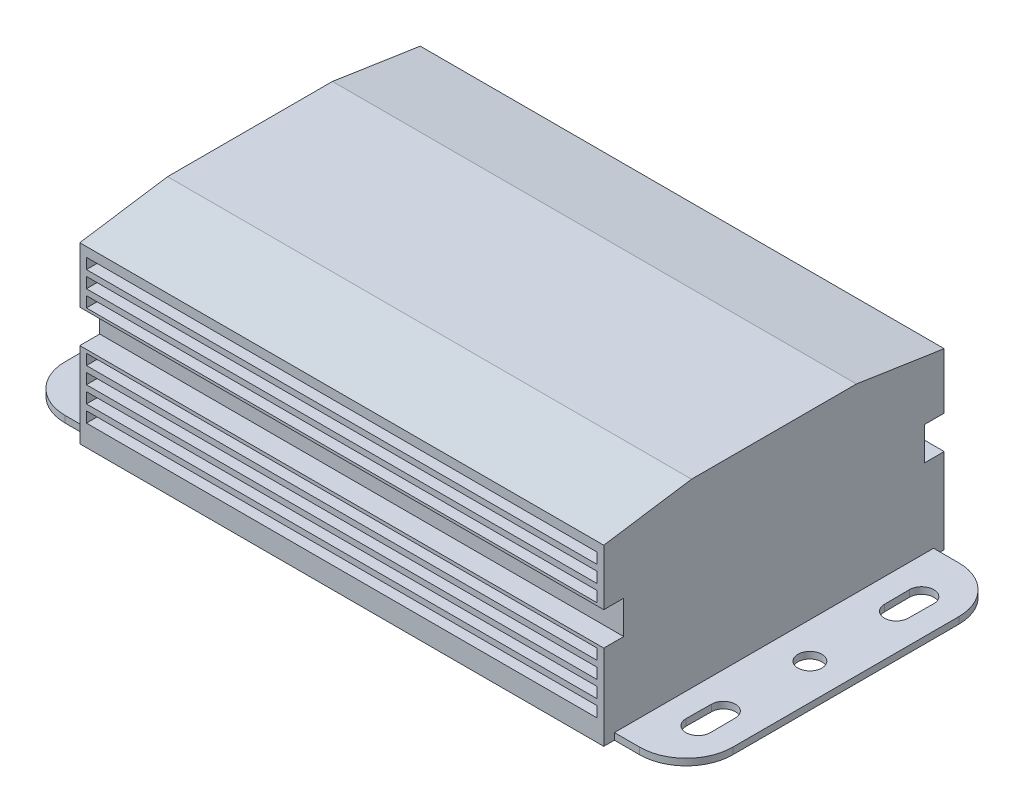
from build123d import *

# Parameters (mm, degrees)
SKETCH1_R               = 2.286
BOSS_EXTRUDE1_DEPTH     = 35.814
SKETCH3_W               = 13.716
SKETCH3_H               = 60.96
CUT_EXTRUDE2_DEPTH      = 34.544
SKETCH4_W               = 3.81
SKETCH4_H               = 6.35
CUT_EXTRUDE3_DEPTH      = 114.792
SKETCH5_W               = 97.536
SKETCH5_H               = 2.032
CUT_EXTRUDE6_DEPTH      = 3.048
LPATTERN1_COUNT         = 9
LPATTERN1_PITCH         = 3.175
MIRROR1_COPY_1_SKETCH_W = 97.536
MIRROR1_COPY_1_SKETCH_H = 2.032
MIRROR1_COPY_1_DEPTH    = 3.048
MIRROR1_COPY_2_SKETCH_W = 97.536
MIRROR1_COPY_2_SKETCH_H = 2.032
MIRROR1_COPY_2_DEPTH    = 3.048
MIRROR1_COPY_3_SKETCH_W = 97.536
MIRROR1_COPY_3_SKETCH_H = 2.032
MIRROR1_COPY_3_DEPTH    = 3.048
MIRROR1_COPY_4_SKETCH_W = 97.536
MIRROR1_COPY_4_SKETCH_H = 2.032
MIRROR1_COPY_4_DEPTH    = 3.048
MIRROR1_COPY_5_SKETCH_W = 97.536
MIRROR1_COPY_5_SKETCH_H = 2.032
MIRROR1_COPY_5_DEPTH    = 3.048
MIRROR1_COPY_6_SKETCH_W = 97.536
MIRROR1_COPY_6_SKETCH_H = 2.032
MIRROR1_COPY_6_DEPTH    = 3.048


with BuildPart() as part:
    # Sketch1 → Boss-Extrude1 (new body)
    with BuildSketch(Plane(origin=(0, 0, 0), x_dir=(1, 0, 0), z_dir=(0, 1, 0))):
        with BuildLine():
            Line((0, 11.938), (0, 55.118))
            ThreePointArc((0, 55.118), (-2.603820715, 61.404179285), (-8.89, 64.008))
            Line((-8.89, 64.008), (-13.716, 64.008))
            Line((-13.716, 64.008), (-13.716, 66.04))
            Line((-13.716, 66.04), (-113.792, 66.04))
            Line((-113.792, 66.04), (-113.792, 64.008))
            Line((-113.792, 64.008), (-118.618, 64.008))
            ThreePointArc((-118.618, 64.008), (-124.904179285, 61.404179285), (-127.508, 55.118))
            Line((-127.508, 55.118), (-127.508, 11.938))
            ThreePointArc((-127.508, 11.938), (-124.904179285, 5.651820715), (-118.618, 3.048))
            Line((-118.618, 3.048), (-113.792, 3.048))
            Line((-113.792, 3.048), (-113.792, 1.016))
            Line((-113.792, 1.016), (-13.716, 1.016))
            Line((-13.716, 1.016), (-13.716, 3.048))
            Line((-13.716, 3.048), (-8.89, 3.048))
            ThreePointArc((-8.89, 3.048), (-2.603820715, 5.651820715), (0, 11.938))
        make_face()
        with Locations((-120.65, 33.528)):
            Circle(SKETCH1_R, mode=Mode.SUBTRACT)
        with Locations((-6.858, 33.528)):
            Circle(SKETCH1_R, mode=Mode.SUBTRACT)
        with BuildLine():
            Line((-118.367709413, 17.018), (-118.325280939, 12.192))
            ThreePointArc((-118.325280939, 12.192), (-120.65, 9.867280939), (-122.974719061, 12.192))
            Line((-122.974719061, 12.192), (-122.932290587, 17.018))
            ThreePointArc((-122.932290587, 17.018), (-120.65, 19.300290587), (-118.367709413, 17.018))
        make_face(mode=Mode.SUBTRACT)
        with BuildLine():
            Line((-122.974719061, 54.864), (-122.932290587, 50.038))
            ThreePointArc((-122.932290587, 50.038), (-120.65, 47.755709413), (-118.367709413, 50.038))
            Line((-118.367709413, 50.038), (-118.325280939, 54.864))
            ThreePointArc((-118.325280939, 54.864), (-120.65, 57.188719061), (-122.974719061, 54.864))
        make_face(mode=Mode.SUBTRACT)
        with BuildLine():
            Line((-9.140290587, 50.038), (-9.182719061, 54.864))
            ThreePointArc((-9.182719061, 54.864), (-6.858, 57.188719061), (-4.533280939, 54.864))
            Line((-4.533280939, 54.864), (-4.575709413, 50.038))
            ThreePointArc((-4.575709413, 50.038), (-6.858, 47.755709413), (-9.140290587, 50.038))
        make_face(mode=Mode.SUBTRACT)
        with BuildLine():
            Line((-4.533280939, 12.192), (-4.575709413, 17.018))
            ThreePointArc((-4.575709413, 17.018), (-6.858, 19.300290587), (-9.140290587, 17.018))
            Line((-9.140290587, 17.018), (-9.182719061, 12.192))
            ThreePointArc((-9.182719061, 12.192), (-6.858, 9.867280939), (-4.533280939, 12.192))
        make_face(mode=Mode.SUBTRACT)
    extrude(amount=BOSS_EXTRUDE1_DEPTH)

    # Sketch3 → Cut-Extrude2 (cut)
    with BuildSketch(Plane(origin=(0, 35.814, 0), x_dir=(1, 0, 0), z_dir=(0, 1, 0))):
        with Locations((-6.858, 33.528)):
            Rectangle(SKETCH3_W, SKETCH3_H)
        with Locations((-120.65, 33.528)):
            Rectangle(SKETCH3_W, SKETCH3_H)
    extrude(amount=-CUT_EXTRUDE2_DEPTH, mode=Mode.SUBTRACT)

    # Sketch4 → Cut-Extrude3 (cut, through all)
    with BuildSketch(Plane.ZY.offset(113.792)):
        Polygon((-17.78, 35.814), (-1.016, 33.274), (-1.016, 35.814), align=None)
        with Locations((-64.135, 19.431)):
            Rectangle(SKETCH4_W, SKETCH4_H)
        with Locations((-2.921, 19.431)):
            Rectangle(SKETCH4_W, SKETCH4_H)
        Polygon((-66.04, 33.274), (-66.04, 35.814), (-49.276, 35.814), align=None)
    extrude(amount=-CUT_EXTRUDE3_DEPTH, mode=Mode.SUBTRACT)

    # Sketch5 → Cut-Extrude6 (cut)
    with BuildSketch(Plane.XY.offset(-1.016)):
        with Locations((-63.754, 30.48)):
            Rectangle(SKETCH5_W, SKETCH5_H)
    cut_extrude6 = extrude(amount=-CUT_EXTRUDE6_DEPTH, mode=Mode.SUBTRACT)

    # LPattern1: Cut-Extrude6 ×9, 2 skipped
    with Locations(*[(0, -i * LPATTERN1_PITCH, 0) for i in range(1, LPATTERN1_COUNT) if i not in (3, 4)]):
        add(cut_extrude6, mode=Mode.SUBTRACT)

    # Mirror1: Cut-Extrude6 across plane
    add(cut_extrude6.mirror(Plane.XY.offset(-33.528)), mode=Mode.SUBTRACT)

    # Mirror1 copy 1 sketch → Mirror1 copy 1 (cut)
    with BuildSketch(Plane(origin=(0, -3.175, -66.04), x_dir=(1, 0, 0), z_dir=(0, 0, -1))):
        with Locations((-63.754, -30.48)):
            Rectangle(MIRROR1_COPY_1_SKETCH_W, MIRROR1_COPY_1_SKETCH_H)
    extrude(amount=-MIRROR1_COPY_1_DEPTH, mode=Mode.SUBTRACT)

    # Mirror1 copy 2 sketch → Mirror1 copy 2 (cut)
    with BuildSketch(Plane(origin=(0, -6.35, -66.04), x_dir=(1, 0, 0), z_dir=(0, 0, -1))):
        with Locations((-63.754, -30.48)):
            Rectangle(MIRROR1_COPY_2_SKETCH_W, MIRROR1_COPY_2_SKETCH_H)
    extrude(amount=-MIRROR1_COPY_2_DEPTH, mode=Mode.SUBTRACT)

    # Mirror1 copy 3 sketch → Mirror1 copy 3 (cut)
    with BuildSketch(Plane(origin=(0, -15.875, -66.04), x_dir=(1, 0, 0), z_dir=(0, 0, -1))):
        with Locations((-63.754, -30.48)):
            Rectangle(MIRROR1_COPY_3_SKETCH_W, MIRROR1_COPY_3_SKETCH_H)
    extrude(amount=-MIRROR1_COPY_3_DEPTH, mode=Mode.SUBTRACT)

    # Mirror1 copy 4 sketch → Mirror1 copy 4 (cut)
    with BuildSketch(Plane(origin=(0, -19.05, -66.04), x_dir=(1, 0, 0), z_dir=(0, 0, -1))):
        with Locations((-63.754, -30.48)):
            Rectangle(MIRROR1_COPY_4_SKETCH_W, MIRROR1_COPY_4_SKETCH_H)
    extrude(amount=-MIRROR1_COPY_4_DEPTH, mode=Mode.SUBTRACT)

    # Mirror1 copy 5 sketch → Mirror1 copy 5 (cut)
    with BuildSketch(Plane(origin=(0, -22.225, -66.04), x_dir=(1, 0, 0), z_dir=(0, 0, -1))):
        with Locations((-63.754, -30.48)):
            Rectangle(MIRROR1_COPY_5_SKETCH_W, MIRROR1_COPY_5_SKETCH_H)
    extrude(amount=-MIRROR1_COPY_5_DEPTH, mode=Mode.SUBTRACT)

    # Mirror1 copy 6 sketch → Mirror1 copy 6 (cut)
    with BuildSketch(Plane(origin=(0, -25.4, -66.04), x_dir=(1, 0, 0), z_dir=(0, 0, -1))):
        with Locations((-63.754, -30.48)):
            Rectangle(MIRROR1_COPY_6_SKETCH_W, MIRROR1_COPY_6_SKETCH_H)
    extrude(amount=-MIRROR1_COPY_6_DEPTH, mode=Mode.SUBTRACT)


solid = part.part
